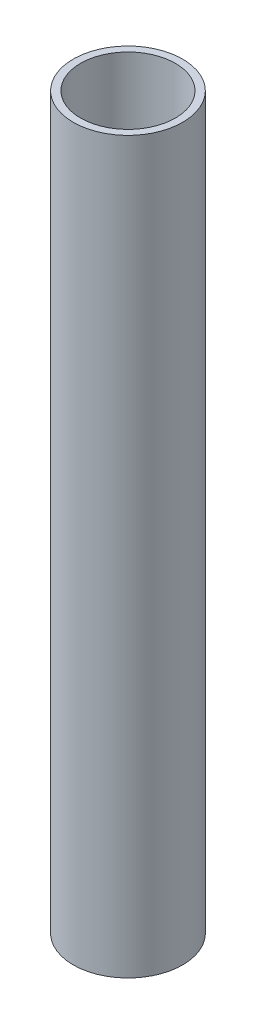
from build123d import *

# Parameters (mm, degrees)
SKETCH_1_R      = 7.5
SKETCH_1_R_2    = 6.5
EXTRUDE_1_DEPTH = 100


with BuildPart() as part:
    # Эскиз1 → Бобышка-Вытянуть1 (new body)
    with BuildSketch(Plane(origin=(0, 0, 0), x_dir=(1, 0, 0), z_dir=(0, 1, 0))):
        Circle(SKETCH_1_R)
        Circle(SKETCH_1_R_2, mode=Mode.SUBTRACT)
    extrude(amount=EXTRUDE_1_DEPTH)


solid = part.part
